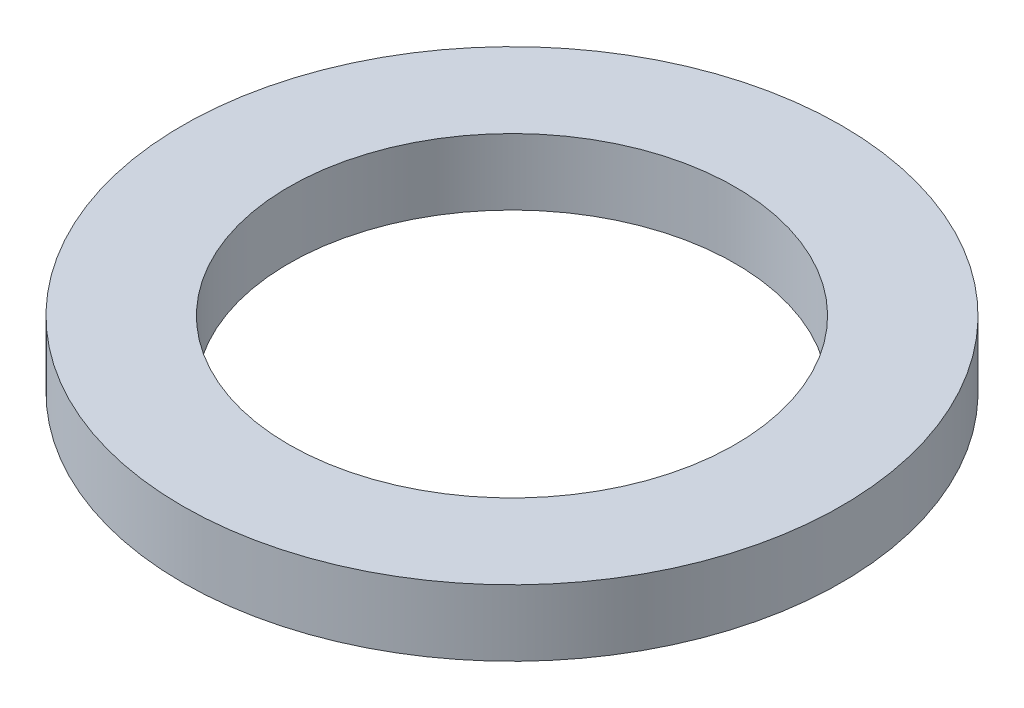
from build123d import *

# Parameters (mm, degrees)
SKETCH1_R           = 40.535
SKETCH1_R_2         = 27.45
BOSS_EXTRUDE1_DEPTH = 8.15


with BuildPart() as part:
    # Sketch1 → Boss-Extrude1 (new body)
    with BuildSketch(Plane(origin=(0, 0, 0), x_dir=(1, 0, 0), z_dir=(0, 1, 0))):
        Circle(SKETCH1_R)
        Circle(SKETCH1_R_2, mode=Mode.SUBTRACT)
    extrude(amount=BOSS_EXTRUDE1_DEPTH)


solid = part.part
